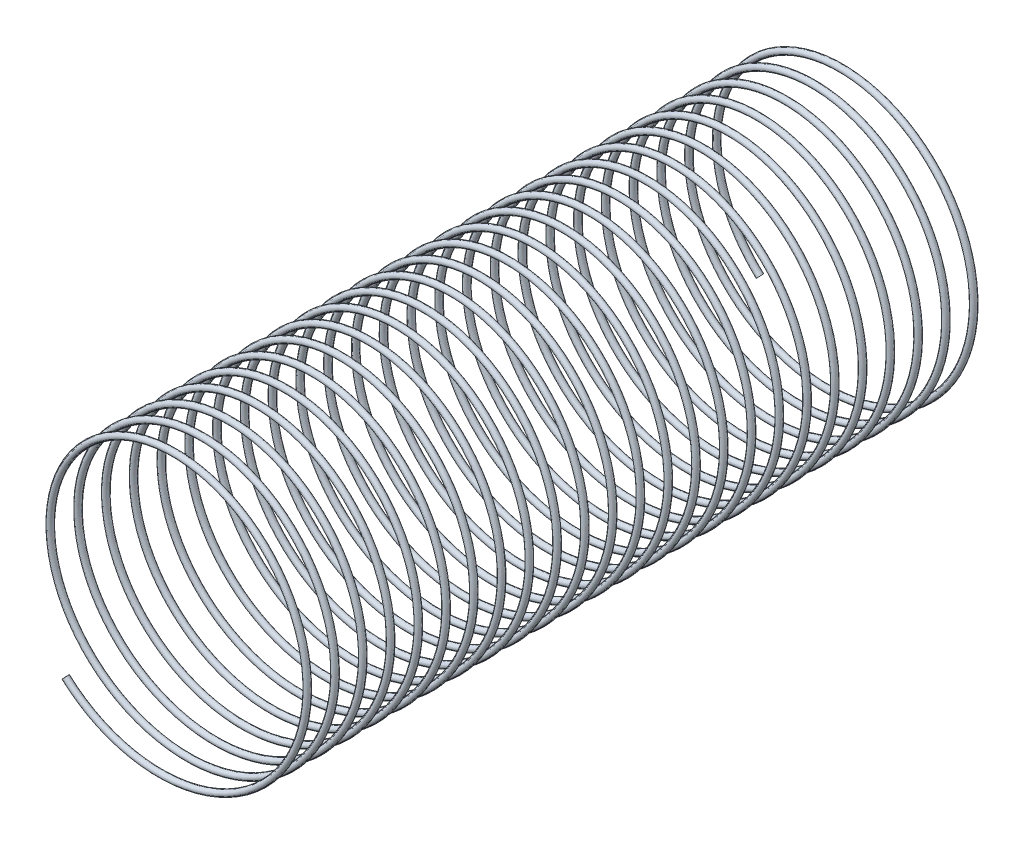
from build123d import *

# Parameters (mm, degrees)
SWEEP2_PITCH       = 2.032
SWEEP2_HEIGHT      = 50.8
SWEEP2_RADIUS      = 9.906
SWEEP2_START_ANGLE = -135
SWEEP2_PROFILE_R   = 0.22733


with BuildPart() as part:
    # Sweep2: sweep along a helix
    with BuildLine() as sweep2_path:
        add(Helix(SWEEP2_PITCH, SWEEP2_HEIGHT, SWEEP2_RADIUS, center=(0, 0, 0), direction=(0, 0, 1), lefthand=True, mode=Mode.PRIVATE).rotate(Axis((0, 0, 0), (0, 0, 1)), SWEEP2_START_ANGLE))
    # Sweep2 profile (on start of the path) → Sweep2 (sweep)
    with BuildSketch(Plane(origin=(-7.004599774, -7.004599774, 0), x_dir=(-0.707106781, -0.707106781, 0), z_dir=(-0.706730252, 0.706730252, 0.032629783))):
        Circle(SWEEP2_PROFILE_R)
    sweep(path=sweep2_path.line, is_frenet=True)


solid = part.part
